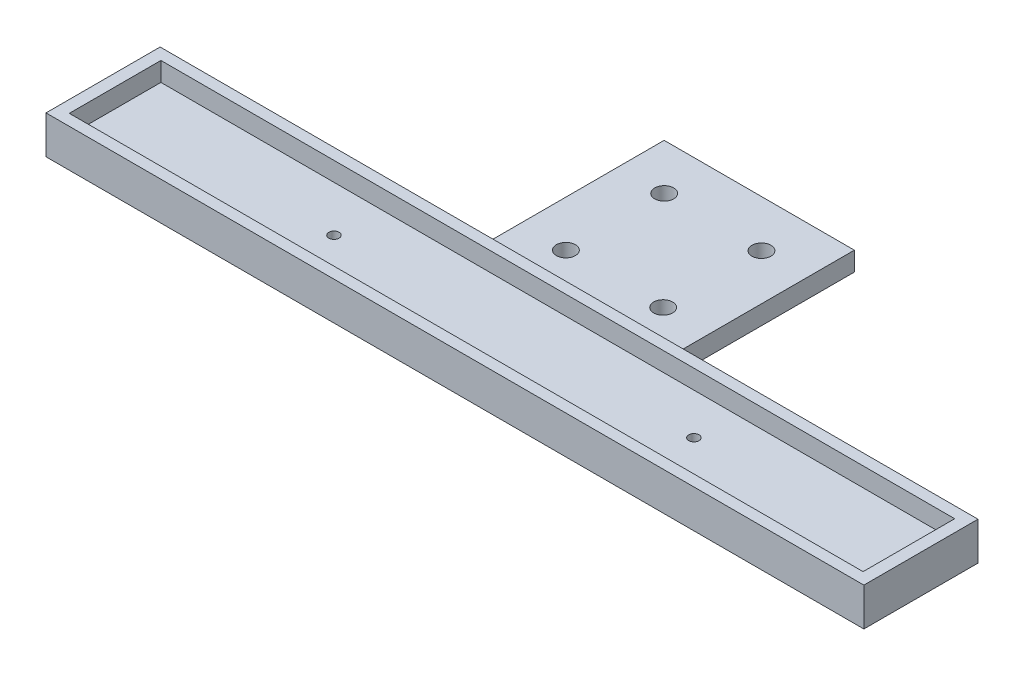
from build123d import *

# Parameters (mm, degrees)
SKETCH1_W           = 129
SKETCH1_H           = 18
SKETCH1_W_2         = 125.2
SKETCH1_H_2         = 14.45
BOSS_EXTRUDE1_DEPTH = 3
SKETCH2_W           = 129
SKETCH2_H           = 18
BOSS_EXTRUDE2_DEPTH = 3
SKETCH4_R           = 0.81
CUT_EXTRUDE1_DEPTH  = 4
SKETCH5_W           = 30
SKETCH5_H           = 30
SKETCH5_R           = 1.5
BOSS_EXTRUDE4_DEPTH = 3


with BuildPart() as part:
    # Sketch1 → Boss-Extrude1 (new body)
    with BuildSketch(Plane(origin=(0, 0, 0), x_dir=(1, 0, 0), z_dir=(0, 1, 0))):
        Rectangle(SKETCH1_W, SKETCH1_H)
        Rectangle(SKETCH1_W_2, SKETCH1_H_2, mode=Mode.SUBTRACT)
    extrude(amount=BOSS_EXTRUDE1_DEPTH)

    # Sketch2 → Boss-Extrude2 (add)
    with BuildSketch(Plane.XZ):
        Rectangle(SKETCH2_W, SKETCH2_H)
    extrude(amount=BOSS_EXTRUDE2_DEPTH)

    # Sketch4 → Cut-Extrude1 (cut, through all)
    with BuildSketch(Plane(origin=(0, 0, 0), x_dir=(1, 0, 0), z_dir=(0, 1, 0))):
        with Locations((27.97, 0.725)):
            Circle(SKETCH4_R)
        with Locations((-28.08, 0)):
            Circle(SKETCH4_R)
    extrude(amount=-CUT_EXTRUDE1_DEPTH, mode=Mode.SUBTRACT)

    # Sketch5 → Boss-Extrude4 (add)
    with BuildSketch(Plane.XZ.offset(3)):
        with Locations((0, -24)):
            Rectangle(SKETCH5_W, SKETCH5_H)
        with Locations((7.75, -16.092702878)):
            Circle(SKETCH5_R, mode=Mode.SUBTRACT)
        with Locations((7.749201838, -31.592702857)):
            Circle(SKETCH5_R, mode=Mode.SUBTRACT)
        with Locations((-7.75, -31.75)):
            Circle(SKETCH5_R, mode=Mode.SUBTRACT)
        with Locations((-7.749201838, -16.250000021)):
            Circle(SKETCH5_R, mode=Mode.SUBTRACT)
    extrude(amount=-BOSS_EXTRUDE4_DEPTH)


solid = part.part
